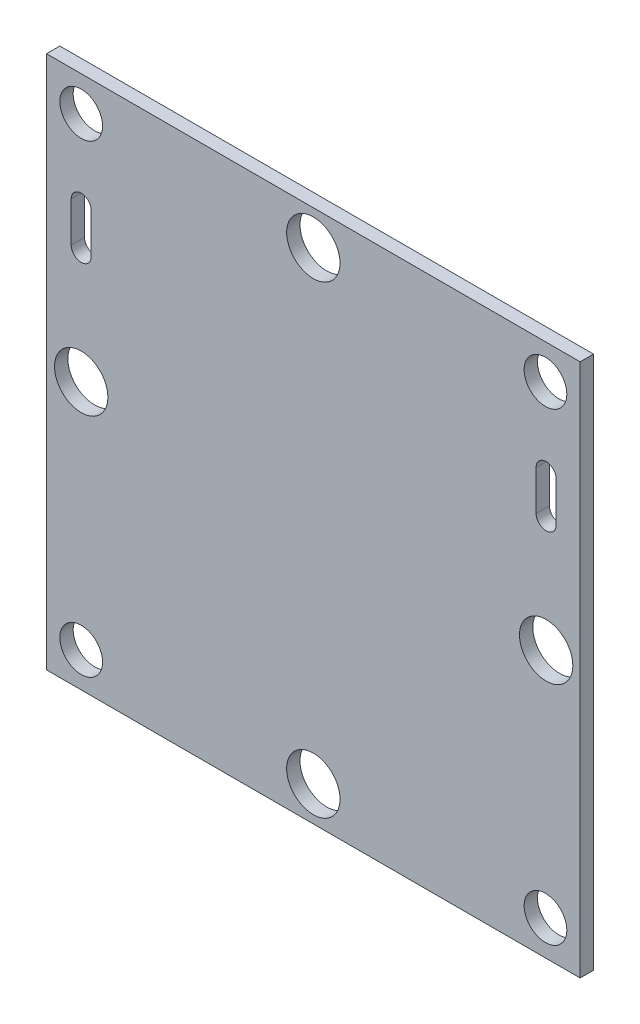
from build123d import *

# Parameters (mm, degrees)
SKETCH1_W           = 40
SKETCH1_H           = 40
BOSS_EXTRUDE1_DEPTH = 1
SKETCH2_R           = 1.6
SKETCH2_R_2         = 2
CUT_EXTRUDE1_DEPTH  = 10


with BuildPart() as part:
    # Sketch1 → Boss-Extrude1 (new body)
    with BuildSketch(Plane.XY):
        Rectangle(SKETCH1_W, SKETCH1_H)
    extrude(amount=BOSS_EXTRUDE1_DEPTH)

    # Sketch2 → Cut-Extrude1 (cut)
    with BuildSketch(Plane.XY.offset(1)):
        with Locations((-17.4, -17.4)):
            Circle(SKETCH2_R)
        with Locations((17.4, -17.4)):
            Circle(SKETCH2_R)
        with Locations((17.4, 17.4)):
            Circle(SKETCH2_R)
        with Locations((-17.4, 17.4)):
            Circle(SKETCH2_R)
        with Locations((0, 17.4)):
            Circle(SKETCH2_R_2)
        with Locations((17.450650527, 0)):
            Circle(SKETCH2_R_2)
        with Locations((0, -17.4)):
            Circle(SKETCH2_R_2)
        with Locations((-17.4, 0)):
            Circle(SKETCH2_R_2)
        with BuildLine():
            Line((-16.65, 11.5), (-16.65, 8.5))
            ThreePointArc((-16.65, 8.5), (-17.4, 7.75), (-18.15, 8.5))
            Line((-18.15, 8.5), (-18.15, 11.5))
            ThreePointArc((-18.15, 11.5), (-17.4, 12.25), (-16.65, 11.5))
        make_face()
        with BuildLine():
            Line((18.200650527, 11.5), (18.200650527, 8.5))
            ThreePointArc((18.200650527, 8.5), (17.450650527, 7.75), (16.700650527, 8.5))
            Line((16.700650527, 8.5), (16.700650527, 11.5))
            ThreePointArc((16.700650527, 11.5), (17.450650527, 12.25), (18.200650527, 11.5))
        make_face()
    extrude(amount=-CUT_EXTRUDE1_DEPTH, mode=Mode.SUBTRACT)


solid = part.part
